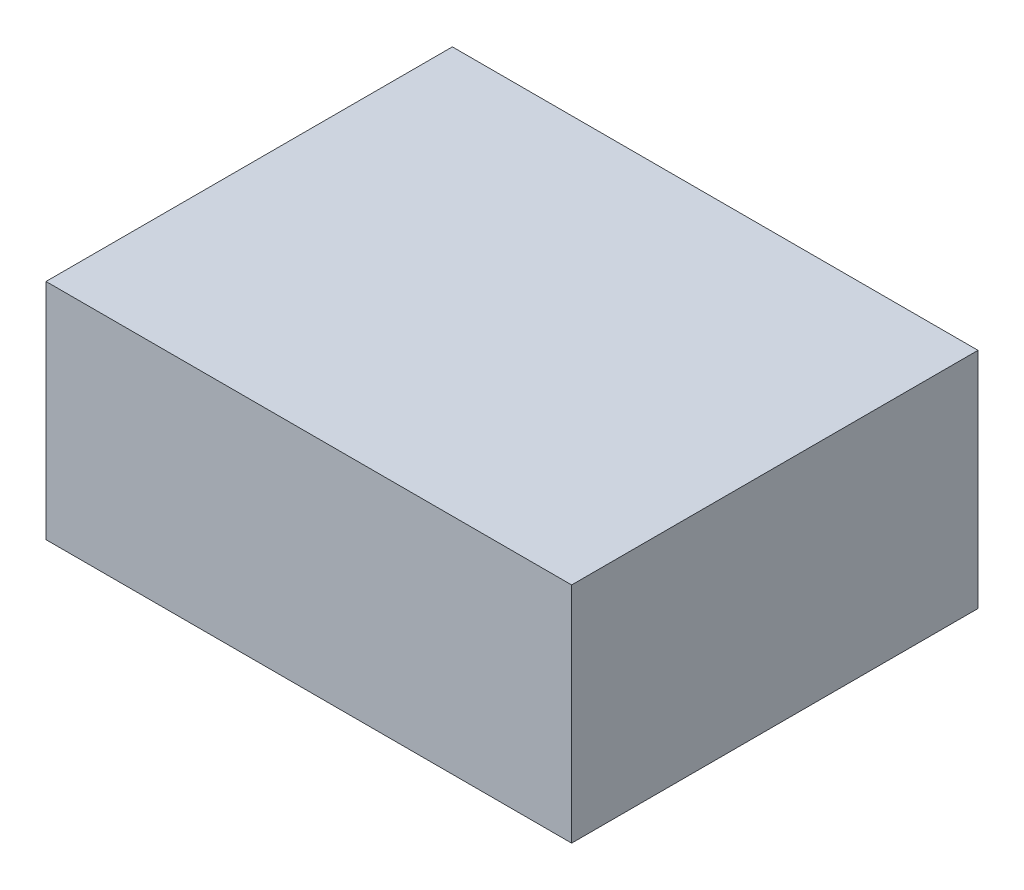
from build123d import *

# Parameters (mm, degrees)
SKETCH1_W           = 109.3
SKETCH1_H           = 84.5
BOSS_EXTRUDE3_DEPTH = 46.5


with BuildPart() as part:
    # Sketch1 → Boss-Extrude3 (new body)
    with BuildSketch(Plane(origin=(0, 0, 0), x_dir=(1, 0, 0), z_dir=(0, 1, 0))):
        with Locations((54.65, 42.25)):
            Rectangle(SKETCH1_W, SKETCH1_H)
    extrude(amount=BOSS_EXTRUDE3_DEPTH)


solid = part.part
